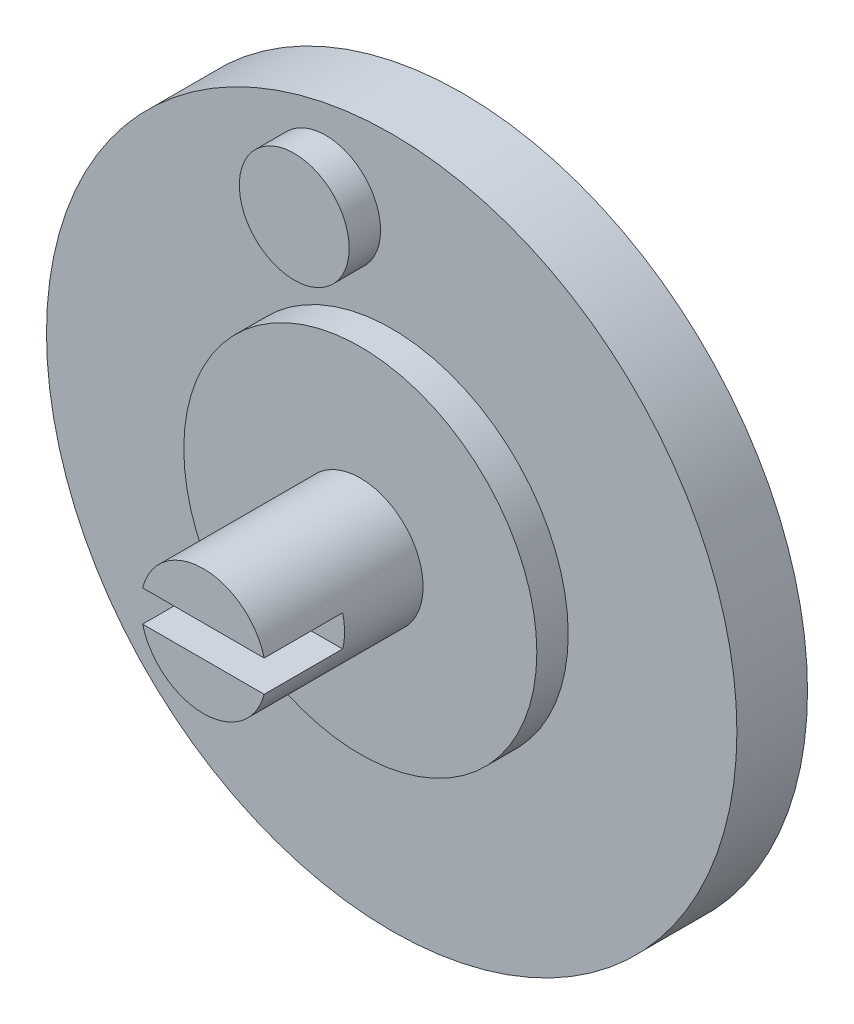
from build123d import *

# Parameters (mm, degrees)
SKETCH1_R           = 22
BOSS_EXTRUDE1_DEPTH = 4.5
BOSS_EXTRUDE2_START = 4.5
SKETCH2_R           = 11.25
BOSS_EXTRUDE2_DEPTH = 2
BOSS_EXTRUDE3_START = 4.5
SKETCH3_R           = 3.5
BOSS_EXTRUDE3_DEPTH = 2
BOSS_EXTRUDE4_START = 6.5
SKETCH4_R           = 4
BOSS_EXTRUDE4_DEPTH = 10
CUT_EXTRUDE1_START  = 16.5
SKETCH5_W           = 54.287880581
SKETCH5_H           = 2
CUT_EXTRUDE1_DEPTH  = 5
SKETCH6_R           = 13
CUT_EXTRUDE2_DEPTH  = 4


with BuildPart() as part:
    # Sketch1 → Boss-Extrude1 (new body)
    with BuildSketch(Plane.XY):
        Circle(SKETCH1_R)
    extrude(amount=BOSS_EXTRUDE1_DEPTH)

    # Sketch2 → Boss-Extrude2 (add)
    with BuildSketch(Plane.XY.offset(BOSS_EXTRUDE2_START)):
        Circle(SKETCH2_R)
    extrude(amount=BOSS_EXTRUDE2_DEPTH)

    # Sketch3 → Boss-Extrude3 (add)
    with BuildSketch(Plane.XY.offset(BOSS_EXTRUDE3_START)):
        with Locations((-4.210444621, 16.315472905)):
            Circle(SKETCH3_R)
    extrude(amount=BOSS_EXTRUDE3_DEPTH)

    # Sketch4 → Boss-Extrude4 (add)
    with BuildSketch(Plane.XY.offset(BOSS_EXTRUDE4_START)):
        Circle(SKETCH4_R)
    extrude(amount=BOSS_EXTRUDE4_DEPTH)

    # Sketch5 → Cut-Extrude1 (cut)
    with BuildSketch(Plane.XY.offset(CUT_EXTRUDE1_START)):
        with Locations((2.276588541, 0)):
            Rectangle(SKETCH5_W, SKETCH5_H)
    extrude(amount=-CUT_EXTRUDE1_DEPTH, mode=Mode.SUBTRACT)

    # Sketch6 → Cut-Extrude2 (cut)
    with BuildSketch(Plane.XY):
        Circle(SKETCH6_R)
    extrude(amount=CUT_EXTRUDE2_DEPTH, mode=Mode.SUBTRACT)


solid = part.part
